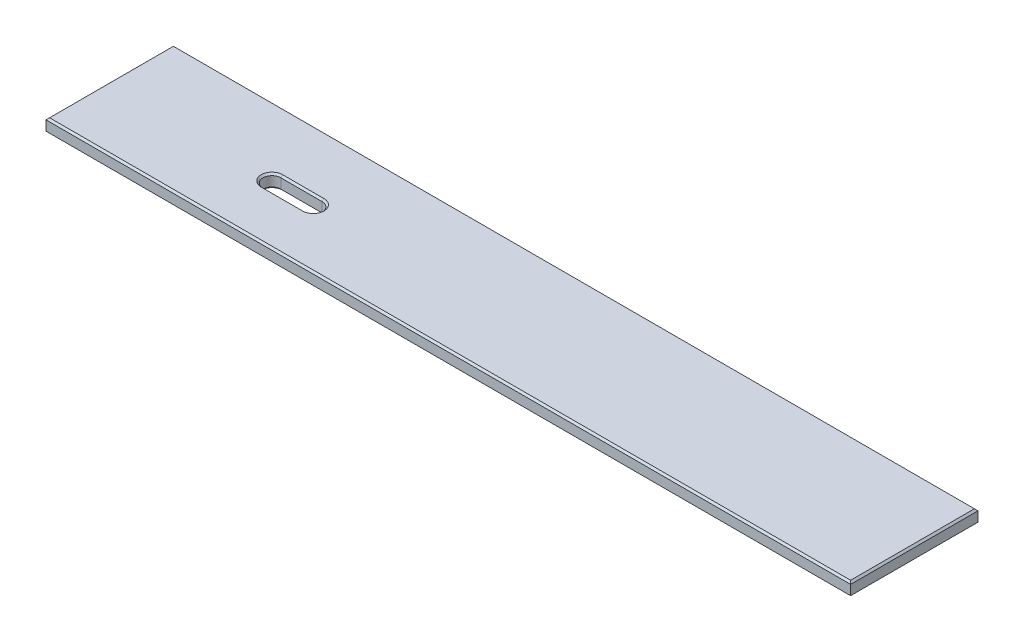
from build123d import *

# Parameters (mm, degrees)
SKETCH1_W           = 1143
SKETCH1_H           = 180.975
BOSS_EXTRUDE1_DEPTH = 19.05
CHAMFER1_SIZE       = 2.54
CHAMFER2_SIZE       = 2.54


with BuildPart() as part:
    # Sketch1 → Boss-Extrude1 (new body)
    with BuildSketch(Plane(origin=(0, 0, 0), x_dir=(1, 0, 0), z_dir=(0, 1, 0))):
        with Locations((571.5, 90.4875)):
            Rectangle(SKETCH1_W, SKETCH1_H)
        with BuildLine():
            Line((238.125, 95.4913), (296.8752, 95.4913))
            ThreePointArc((296.8752, 95.4913), (309.5752, 82.7913), (296.8752, 70.0913))
            Line((296.8752, 70.0913), (238.125, 70.0913))
            ThreePointArc((238.125, 70.0913), (225.425, 82.7913), (238.125, 95.4913))
        make_face(mode=Mode.SUBTRACT)
    extrude(amount=BOSS_EXTRUDE1_DEPTH)

    # Chamfer1
    chamfer1_edges = [part.edges().sort_by_distance(p)[0] for p in [
        (1143, 19.05, -90.4875),
        (309.5752, 19.05, -82.7913),
        (571.5, 19.05, -180.975),
        (267.5001, 19.05, -95.4913),
        (225.425, 19.05, -82.7913),
        (267.5001, 19.05, -70.0913),
        (0, 19.05, -90.4875),
        (571.5, 19.05, 0),
    ]]
    chamfer(chamfer1_edges, length=CHAMFER1_SIZE)

    # Chamfer2
    chamfer2_edges = [part.edges().sort_by_distance(p)[0] for p in [
        (309.5752, 0, -82.7913),
        (267.5001, 0, -95.4913),
        (225.425, 0, -82.7913),
        (267.5001, 0, -70.0913),
        (571.5, 0, -180.975),
        (1143, 0, -90.4875),
        (571.5, 0, 0),
        (0, 0, -90.4875),
    ]]
    chamfer(chamfer2_edges, length=CHAMFER2_SIZE)


solid = part.part
